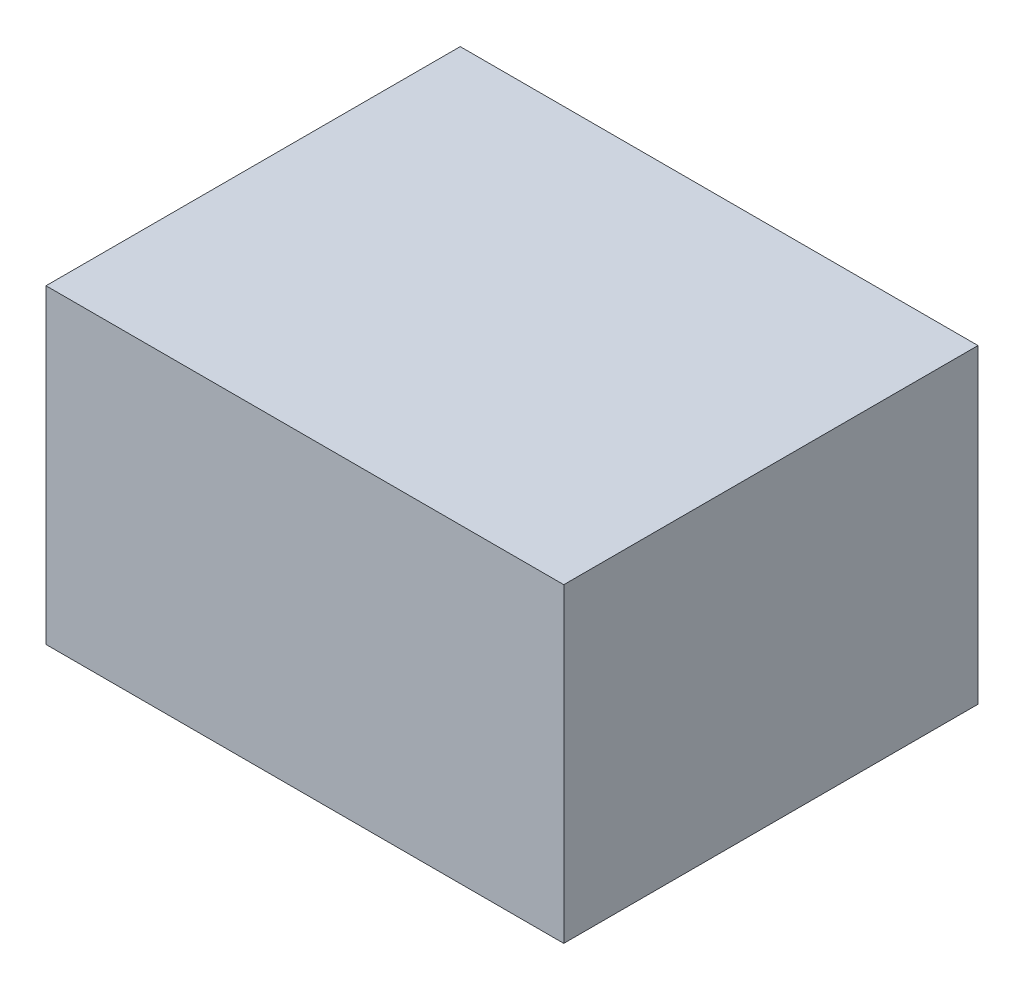
from build123d import *

# Parameters (mm, degrees)
SKETCH1_W           = 254
SKETCH1_H           = 203.2
BOSS_EXTRUDE1_DEPTH = 152.4


with BuildPart() as part:
    # Sketch1 → Boss-Extrude1 (new body)
    with BuildSketch(Plane(origin=(0, 0, 0), x_dir=(1, 0, 0), z_dir=(0, 1, 0))):
        Rectangle(SKETCH1_W, SKETCH1_H)
    extrude(amount=BOSS_EXTRUDE1_DEPTH)


solid = part.part
